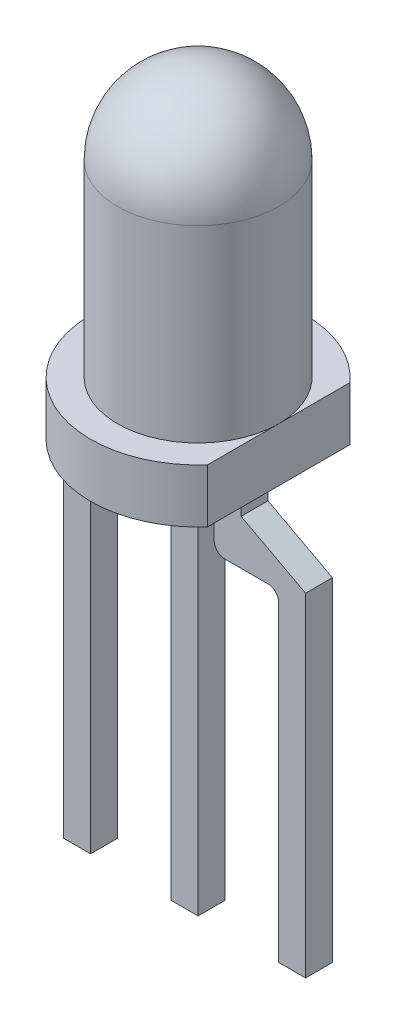
from build123d import *

# Parameters (mm, degrees)
ESBO_O1_W                       = 0.5
ESBO_O1_H                       = 0.5
RESSALTO_EXTRUS_O1_DEPTH        = 1
RESSALTO_EXTRUS_O1_DEPTH_BACK   = 4
RESSALTO_EXTRUS_O1_2_DEPTH      = 1
RESSALTO_EXTRUS_O1_2_DEPTH_BACK = 4
RESSALTO_EXTRUS_O1_3_DEPTH      = 1
RESSALTO_EXTRUS_O1_3_DEPTH_BACK = 4
ESBO_O2_W                       = 0.5
ESBO_O2_H                       = 2.43
RESSALTO_EXTRUS_O2_DEPTH        = 0.5
RESSALTO_EXTRUS_O3_DEPTH        = 1


with BuildPart() as part:
    # Esboço1 → Ressalto-extrusão1 (new body, two sides)
    with BuildSketch(Plane(origin=(0, 0, 0), x_dir=(1, 0, 0), z_dir=(0, 1, 0))) as ressalto_extrus_o1_sk:
        Rectangle(ESBO_O1_W, ESBO_O1_H)
    extrude(amount=RESSALTO_EXTRUS_O1_DEPTH)
    extrude(ressalto_extrus_o1_sk.sketch, amount=-RESSALTO_EXTRUS_O1_DEPTH_BACK)



with BuildPart() as body_2:
    # Esboço1 → Ressalto-extrus_o1 2 (new body, two sides)
    with BuildSketch(Plane(origin=(0, 0, 0), x_dir=(1, 0, 0), z_dir=(0, 1, 0))) as ressalto_extrus_o1_2_sk:
        with Locations((2, 0)):
            Rectangle(ESBO_O1_W, ESBO_O1_H)
    extrude(amount=RESSALTO_EXTRUS_O1_2_DEPTH)
    extrude(ressalto_extrus_o1_2_sk.sketch, amount=-RESSALTO_EXTRUS_O1_2_DEPTH_BACK)


with BuildPart() as body_3:
    # Esboço1 → Ressalto-extrus_o1 3 (new body, two sides)
    with BuildSketch(Plane(origin=(0, 0, 0), x_dir=(1, 0, 0), z_dir=(0, 1, 0))) as ressalto_extrus_o1_3_sk:
        with Locations((-2, 0)):
            Rectangle(ESBO_O1_W, ESBO_O1_H)
    extrude(amount=RESSALTO_EXTRUS_O1_3_DEPTH)
    extrude(ressalto_extrus_o1_3_sk.sketch, amount=-RESSALTO_EXTRUS_O1_3_DEPTH_BACK)


with BuildPart() as part_1:
    add(part.part)

    add(body_2.part)  # Ressalto-extrusão2 merges body 2

    add(body_3.part)  # Ressalto-extrusão2 merges body 3
    # Esboço2 → Ressalto-extrusão2 (add)
    with BuildSketch(Plane.XY.offset(0.25)):
        with BuildLine():
            Line((-2.25, 2.2), (-2.25, 1))
            Line((-2.25, 1), (-1.75, 1))
            Line((-1.75, 1), (-1.75, 1.8))
            ThreePointArc((-1.75, 1.8), (-1.691421356, 1.941421356), (-1.55, 2))
            Line((-1.55, 2), (-0.867667764, 2))
            ThreePointArc((-0.867667764, 2), (-0.726246408, 2.058578644), (-0.667667764, 2.2))
            Line((-0.667667764, 2.2), (-0.667667764, 2.376879859))
            Line((-0.667667764, 2.376879859), (-0.55, 2.479277604))
            Line((-0.55, 2.479277604), (-0.55, 3.43))
            Line((-0.55, 3.43), (-1.05, 3.43))
            Line((-1.05, 3.43), (-1.05, 2.83866396))
            Line((-1.05, 2.83866396), (-2.25, 2.2))
        make_face()
        with Locations((0, 2.215)):
            Rectangle(ESBO_O2_W, ESBO_O2_H)
        with BuildLine():
            Line((1.75, 1), (1.75, 1.8))
            ThreePointArc((1.75, 1.8), (1.691421356, 1.941421356), (1.55, 2))
            Line((1.55, 2), (0.75, 2))
            ThreePointArc((0.75, 2), (0.608578644, 2.058578644), (0.55, 2.2))
            Line((0.55, 2.2), (0.55, 3.43))
            Line((0.55, 3.43), (1.05, 3.43))
            Line((1.05, 3.43), (1.05, 2.83866396))
            Line((1.05, 2.83866396), (2.25, 2.2))
            Line((2.25, 2.2), (2.25, 1))
            Line((2.25, 1), (1.75, 1))
        make_face()
    extrude(amount=-RESSALTO_EXTRUS_O2_DEPTH)

    # Esboço3 → Ressalto-extrusão3 (add)
    with BuildSketch(Plane(origin=(0, 3.43, 0), x_dir=(1, 0, 0), z_dir=(0, 1, 0))):
        with BuildLine():
            Line((1.5, 1.322875656), (1.5, -1.322875656))
            ThreePointArc((1.5, -1.322875656), (-2, 0), (1.5, 1.322875656))
        make_face()
    extrude(amount=RESSALTO_EXTRUS_O3_DEPTH)

    # Esboço4 → Revolução1 (revolve)
    with BuildSketch(Plane.XY):
        with BuildLine():
            Line((0, 4.43), (1.5, 4.43))
            Line((1.5, 4.43), (1.5, 7.93))
            ThreePointArc((1.5, 7.93), (1.060660172, 8.990660172), (0, 9.43))
            Line((0, 9.43), (0, 4.43))
        make_face()
    revolve(axis=Axis((0, 4.43, 0), (0, 1, 0)))


solid = part_1.part
